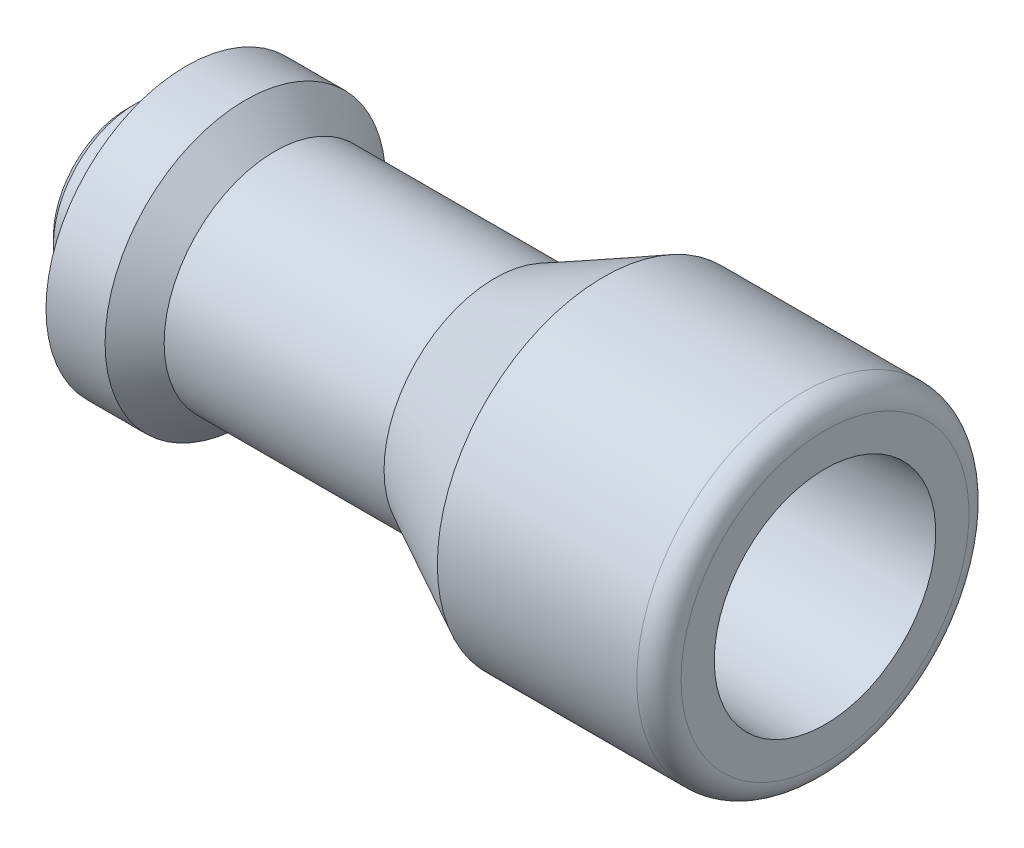
from build123d import *


with BuildPart() as part:
    # Sketch1 → Revolve1 (revolve)
    with BuildSketch(Plane.XY):
        with BuildLine():
            Line((44.5, 5.1), (41.555513627, 0))
            Line((41.555513627, 0), (0, 0))
            Line((0, 0), (0, 10))
            Line((0, 10), (1, 11))
            Line((1, 11), (8, 11))
            Line((8, 11), (8, 19))
            Line((8, 19), (16, 19))
            Line((16, 19), (20, 15))
            Line((20, 15), (49.780421209, 15))
            Line((49.780421209, 15), (64.5, 22.5))
            Line((64.5, 22.5), (91.5, 22.5))
            ThreePointArc((91.5, 22.5), (93.621320344, 21.621320344), (94.5, 19.5))
            Line((94.5, 19.5), (94.5, 15))
            Line((94.5, 15), (67.272080403, 14.049180096))
            ThreePointArc((67.272080403, 14.049180096), (66.72452816, 13.805394131), (66.5, 13.249667434))
            Line((66.5, 13.249667434), (66.5, 5.1))
            Line((66.5, 5.1), (44.5, 5.1))
        make_face()
    revolve(axis=Axis((0, 0, 0), (1, 0, 0)))


solid = part.part
